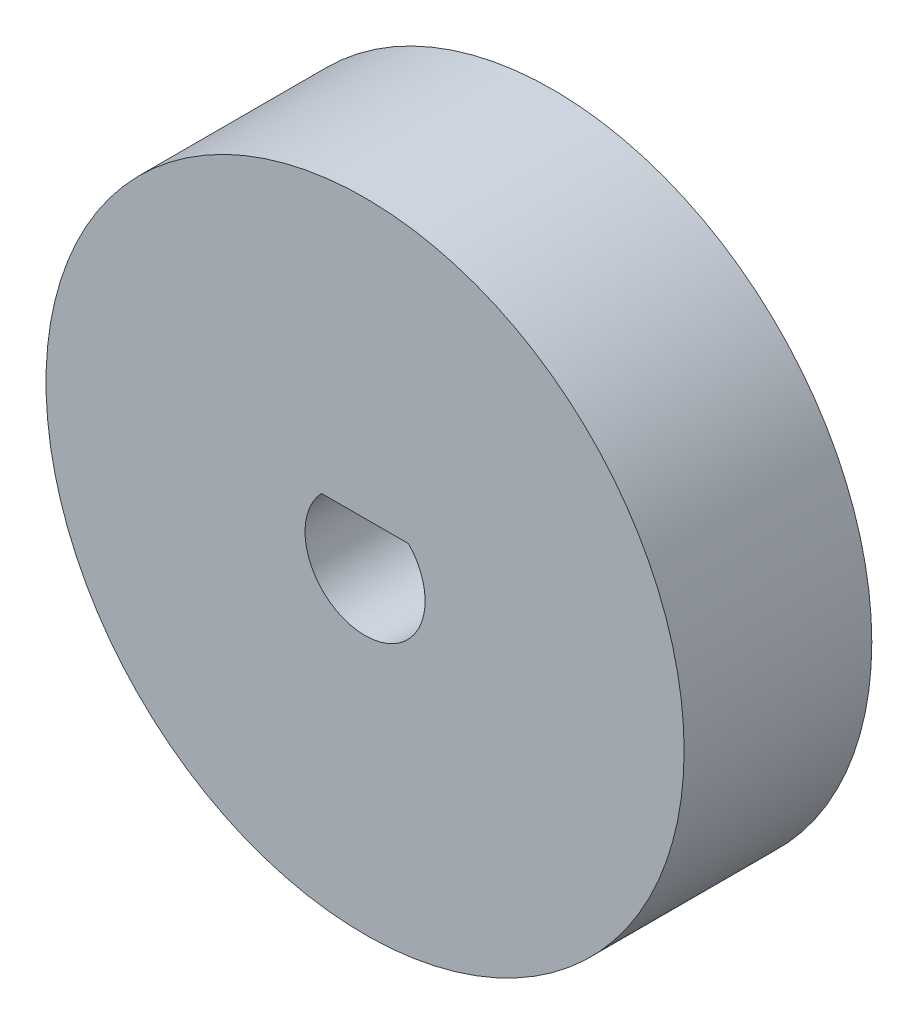
from build123d import *

# Parameters (mm, degrees)
SKETCH2_R           = 8.5
BOSS_EXTRUDE1_DEPTH = 5


with BuildPart() as part:
    # Sketch2 → Boss-Extrude1 (new body)
    with BuildSketch(Plane.XY.offset(8)):
        with Locations((14, 0)):
            Circle(SKETCH2_R)
        with BuildLine():
            ThreePointArc((12.838104996, 1.1), (14, -1.6), (15.161895004, 1.1))
            Line((15.161895004, 1.1), (12.838104996, 1.1))
        make_face(mode=Mode.SUBTRACT)
    extrude(amount=-BOSS_EXTRUDE1_DEPTH)


solid = part.part
